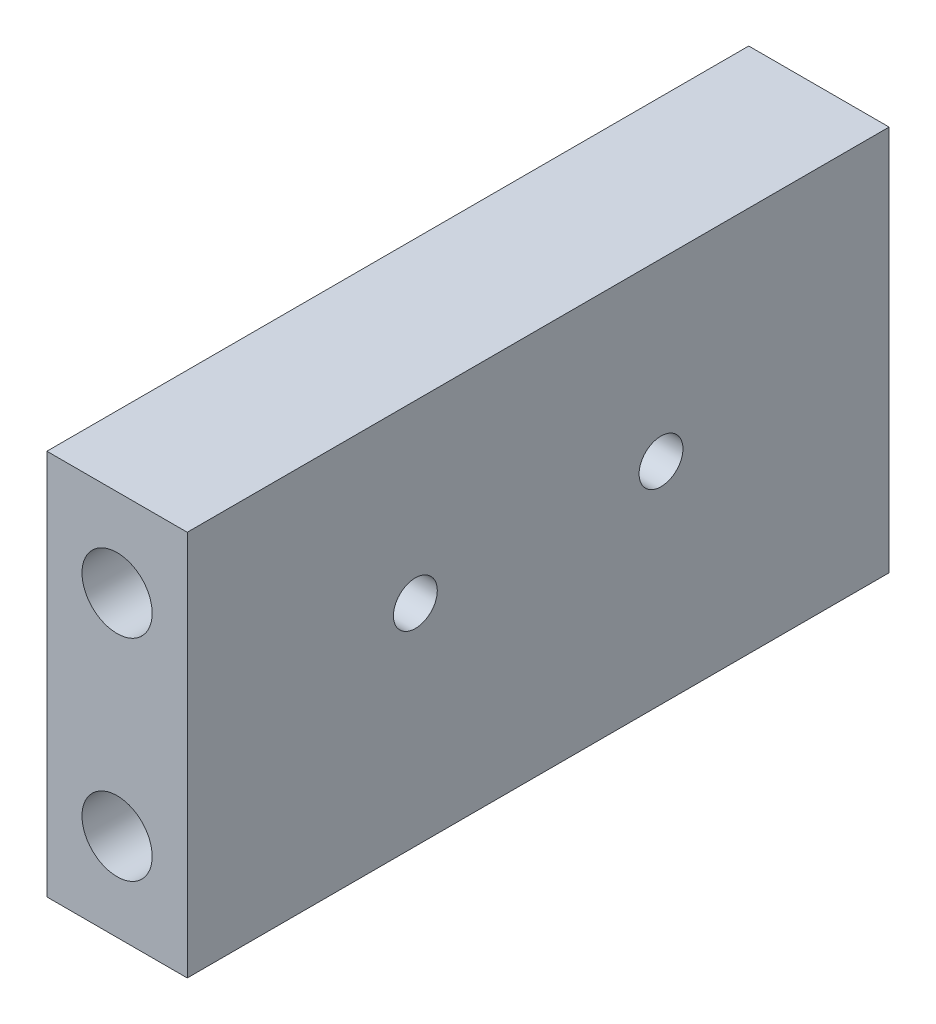
from build123d import *

# Parameters (mm, degrees)
SKETCH1_W           = 127
SKETCH1_H           = 69.85
BOSS_EXTRUDE1_DEPTH = 25.4
SKETCH2_R           = 6.35
CUT_EXTRUDE1_DEPTH  = 25.4
SKETCH3_R           = 3.96875
CUT_EXTRUDE2_DEPTH  = 26.4


with BuildPart() as part:
    # Sketch1 → Boss-Extrude1 (new body)
    with BuildSketch(Plane(origin=(0, 0, 0), x_dir=(0, 0, -1), z_dir=(1, 0, 0))):
        Rectangle(SKETCH1_W, SKETCH1_H)
    extrude(amount=BOSS_EXTRUDE1_DEPTH)

    # Sketch2 → Cut-Extrude1 (cut)
    with BuildSketch(Plane.XY.offset(63.5)):
        with Locations((12.7, 19.05)):
            Circle(SKETCH2_R)
        with Locations((12.7, -19.05)):
            Circle(SKETCH2_R)
    cut_extrude1 = extrude(amount=-CUT_EXTRUDE1_DEPTH, mode=Mode.SUBTRACT)

    # Mirror1: Cut-Extrude1 across plane
    add(cut_extrude1.mirror(Plane.XY), mode=Mode.SUBTRACT)

    # Sketch3 → Cut-Extrude2 (cut, through all)
    with BuildSketch(Plane(origin=(25.4, 0, 0), x_dir=(0, 0, -1), z_dir=(1, 0, 0))):
        with Locations((-22.225, 3.175)):
            Circle(SKETCH3_R)
        with Locations((22.225, 3.175)):
            Circle(SKETCH3_R)
    extrude(amount=-CUT_EXTRUDE2_DEPTH, mode=Mode.SUBTRACT)


solid = part.part
